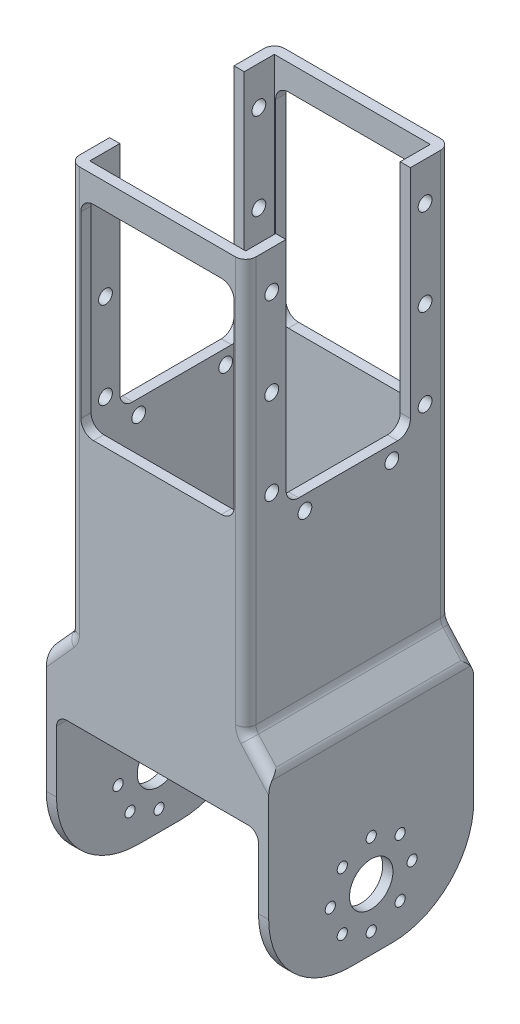
from build123d import *

# Parameters (mm, degrees)
SKETCH1_W               = 43.5
SKETCH1_H               = 40.1
SKETCH1_W_2             = 39.5
SKETCH1_H_2             = 36.1
BOSS_EXTRUDE1_DEPTH     = 40
SKETCH3_R               = 1
SKETCH3_R_2             = 4.25
CUT_EXTRUDE2_DEPTH      = 44.5
SKETCH4_W               = 39.5
SKETCH4_H               = 30
CUT_EXTRUDE3_DEPTH      = 41.1
FILLET1_R               = 16
SKETCH8_W               = 43.5
SKETCH8_H               = 40.1
SKETCH7_W               = 34.5
SKETCH7_H               = 40.1
SKETCH11_W              = 30.5
SKETCH11_H              = 36.1
SKETCH10_W              = 39.5
SKETCH10_H              = 36.1
SKETCH12_W              = 34.5
SKETCH12_H              = 40.1
SKETCH12_W_2            = 30.5
SKETCH12_H_2            = 36.1
BOSS_EXTRUDE2_DEPTH     = 80
SKETCH5_W               = 24.33649167
SKETCH5_H               = 45
CUT_EXTRUDE4_DEPTH      = 5.5000001
CUT_EXTRUDE4_DEPTH_BACK = 40.0000001
SKETCH6_W               = 30
SKETCH6_H               = 40
CUT_EXTRUDE5_DEPTH      = 41.1000001
FILLET2_R               = 2
FILLET3_R               = 2.5
SKETCH16_R              = 1.35
CUT_EXTRUDE6_DEPTH      = 40.0000001


with BuildPart() as part:
    # Sketch1 → Boss-Extrude1 (new body)
    with BuildSketch(Plane(origin=(0, 0, 0), x_dir=(1, 0, 0), z_dir=(0, 1, 0))):
        Rectangle(SKETCH1_W, SKETCH1_H)
        Rectangle(SKETCH1_W_2, SKETCH1_H_2, mode=Mode.SUBTRACT)
    extrude(amount=BOSS_EXTRUDE1_DEPTH)

    # Sketch3 → Cut-Extrude2 (cut, through all)
    with BuildSketch(Plane(origin=(21.75, 0, 0), x_dir=(0, 0, -1), z_dir=(1, 0, 0))):
        with Locations((0, 20)):
            Circle(SKETCH3_R)
        with Locations((5.656854249, 17.656854249)):
            Circle(SKETCH3_R)
        with Locations((8, 12)):
            Circle(SKETCH3_R)
        with Locations((5.656854249, 6.343145751)):
            Circle(SKETCH3_R)
        with Locations((0, 4)):
            Circle(SKETCH3_R)
        with Locations((-5.656854249, 6.343145751)):
            Circle(SKETCH3_R)
        with Locations((-8, 12)):
            Circle(SKETCH3_R)
        with Locations((-5.656854249, 17.656854249)):
            Circle(SKETCH3_R)
        with Locations((0, 12)):
            Circle(SKETCH3_R_2)
    extrude(amount=-CUT_EXTRUDE2_DEPTH, mode=Mode.SUBTRACT)

    # Sketch4 → Cut-Extrude3 (cut, through all)
    with BuildSketch(Plane.XY.offset(20.05)):
        with Locations((0, 15)):
            Rectangle(SKETCH4_W, SKETCH4_H)
    extrude(amount=-CUT_EXTRUDE3_DEPTH, mode=Mode.SUBTRACT)

    # Fillet1
    fillet1_edges = [part.edges().sort_by_distance(p)[0] for p in [
        (20.75, 0, 20.05),
        (-20.75, 0, -20.05),
        (-20.75, 0, 20.05),
        (20.75, 0, -20.05),
    ]]
    fillet(fillet1_edges, radius=FILLET1_R)

    # Sketch8 → Loft2 section 0
    with BuildSketch(Plane(origin=(0, 40, 0), x_dir=(1, 0, 0), z_dir=(0, 1, 0))):
        Rectangle(SKETCH8_W, SKETCH8_H)
    # Sketch7 → Loft2 section 1
    with BuildSketch(Plane(origin=(0, 45, 0), x_dir=(1, 0, 0), z_dir=(0, 1, 0))):
        Rectangle(SKETCH7_W, SKETCH7_H)
    loft()

    # Sketch11 → Cut-Loft1 section 0
    with BuildSketch(Plane(origin=(0, 45, 0), x_dir=(1, 0, 0), z_dir=(0, 1, 0))):
        Rectangle(SKETCH11_W, SKETCH11_H)
    # Sketch10 → Cut-Loft1 section 1
    with BuildSketch(Plane(origin=(0, 40, 0), x_dir=(1, 0, 0), z_dir=(0, 1, 0))):
        Rectangle(SKETCH10_W, SKETCH10_H)
    loft(mode=Mode.SUBTRACT)

    # Sketch12 → Boss-Extrude2 (add)
    with BuildSketch(Plane(origin=(0, 45, 0), x_dir=(1, 0, 0), z_dir=(0, 1, 0))):
        Rectangle(SKETCH12_W, SKETCH12_H)
        Rectangle(SKETCH12_W_2, SKETCH12_H_2, mode=Mode.SUBTRACT)
    extrude(amount=BOSS_EXTRUDE2_DEPTH)

    # Sketch5 → Cut-Extrude4 (cut, two sides)
    with BuildSketch(Plane.ZY.offset(17.25)) as cut_extrude4_sk:
        with Locations((0, 102.5)):
            Rectangle(SKETCH5_W, SKETCH5_H)
    extrude(amount=CUT_EXTRUDE4_DEPTH, mode=Mode.SUBTRACT)
    extrude(cut_extrude4_sk.sketch, amount=-CUT_EXTRUDE4_DEPTH_BACK, mode=Mode.SUBTRACT)

    # Sketch6 → Cut-Extrude5 (cut, through all)
    with BuildSketch(Plane.XY.offset(20.05)):
        with Locations((0, 100)):
            Rectangle(SKETCH6_W, SKETCH6_H)
    extrude(amount=-CUT_EXTRUDE5_DEPTH, mode=Mode.SUBTRACT)

    # Fillet2
    fillet2_edges = [part.edges().sort_by_distance(p)[0] for p in [
        (-19.75, 30, 19.05),
        (19.75, 30, 19.05),
        (19.75, 30, -19.05),
        (-19.75, 30, -19.05),
        (-21.75, 40, 0),
        (17.25, 45, 0),
        (-17.25, 45, 0),
        (19.5, 42.5, 20.05),
        (-19.5, 42.5, 20.05),
        (19.5, 42.5, -20.05),
        (-19.5, 42.5, -20.05),
        (17.25, 85, -20.05),
        (-17.25, 85, -20.05),
        (-17.25, 85, 20.05),
        (17.25, 85, 20.05),
        (21.75, 40, 0),
    ]]
    fillet(fillet2_edges, radius=FILLET2_R)

    # Fillet3
    fillet3_edges = [part.edges().sort_by_distance(p)[0] for p in [
        (-19.75, 40, 0),
        (19.75, 40, 0),
        (15.25, 45, 0),
        (-15.25, 45, 0),
        (16.25, 80, -12.168245835),
        (16.25, 80, 12.168245835),
        (-15, 120, -19.05),
        (-15, 80, -19.05),
        (-16.25, 80, 12.168245835),
        (-16.25, 80, -12.168245835),
        (15, 80, -19.05),
        (15, 120, -19.05),
        (15, 120, 19.05),
        (-15, 120, 19.05),
        (-15, 80, 19.05),
        (15, 80, 19.05),
    ]]
    fillet(fillet3_edges, radius=FILLET3_R)

    # Sketch16 → Cut-Extrude6 (cut, through all)
    with BuildSketch(Plane.ZY.offset(17.25)):
        with Locations((-15.031754165, 117.5)):
            Circle(SKETCH16_R)
        with Locations((-15.031754165, 100.5)):
            Circle(SKETCH16_R)
        with Locations((-15.031754165, 83.5)):
            Circle(SKETCH16_R)
        with Locations((-8.531754165, 77.2)):
            Circle(SKETCH16_R)
        with Locations((8.468245835, 77.2)):
            Circle(SKETCH16_R)
        with Locations((14.968245835, 83.5)):
            Circle(SKETCH16_R)
        with Locations((14.968245835, 100.5)):
            Circle(SKETCH16_R)
        with Locations((14.968245835, 117.5)):
            Circle(SKETCH16_R)
    extrude(amount=-CUT_EXTRUDE6_DEPTH, mode=Mode.SUBTRACT)


solid = part.part
